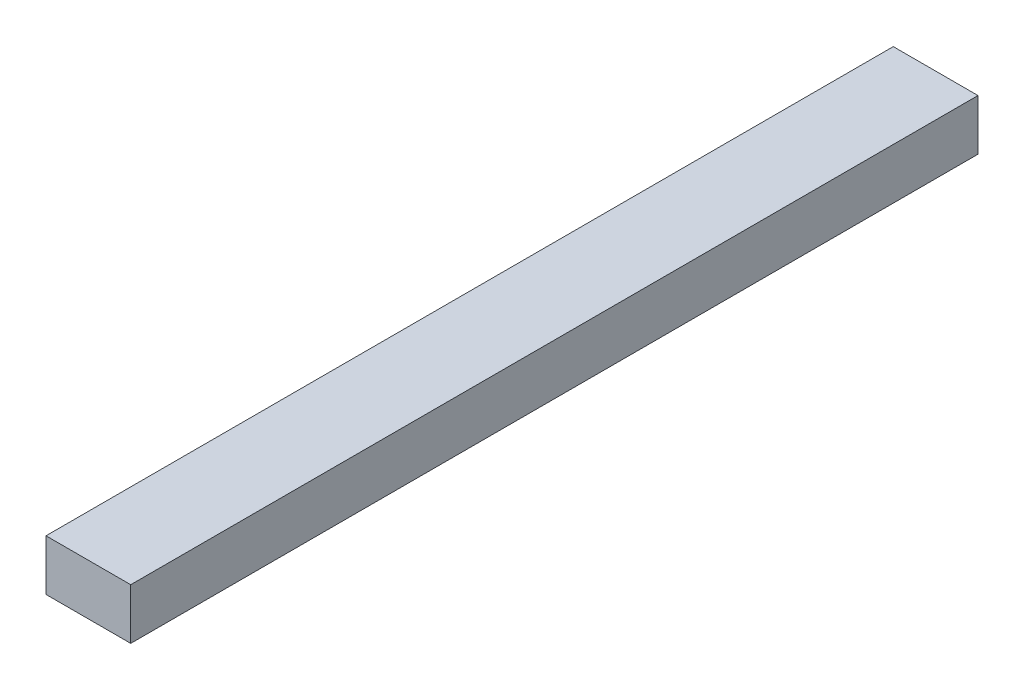
from build123d import *

# Parameters (mm, degrees)
SKETCH2_W           = 5
SKETCH2_H           = 50
BOSS_EXTRUDE1_DEPTH = 3


with BuildPart() as part:
    # Sketch2 → Boss-Extrude1 (new body)
    with BuildSketch(Plane(origin=(0, 0, 0), x_dir=(1, 0, 0), z_dir=(0, 1, 0))):
        Rectangle(SKETCH2_W, SKETCH2_H)
    extrude(amount=BOSS_EXTRUDE1_DEPTH)


solid = part.part
